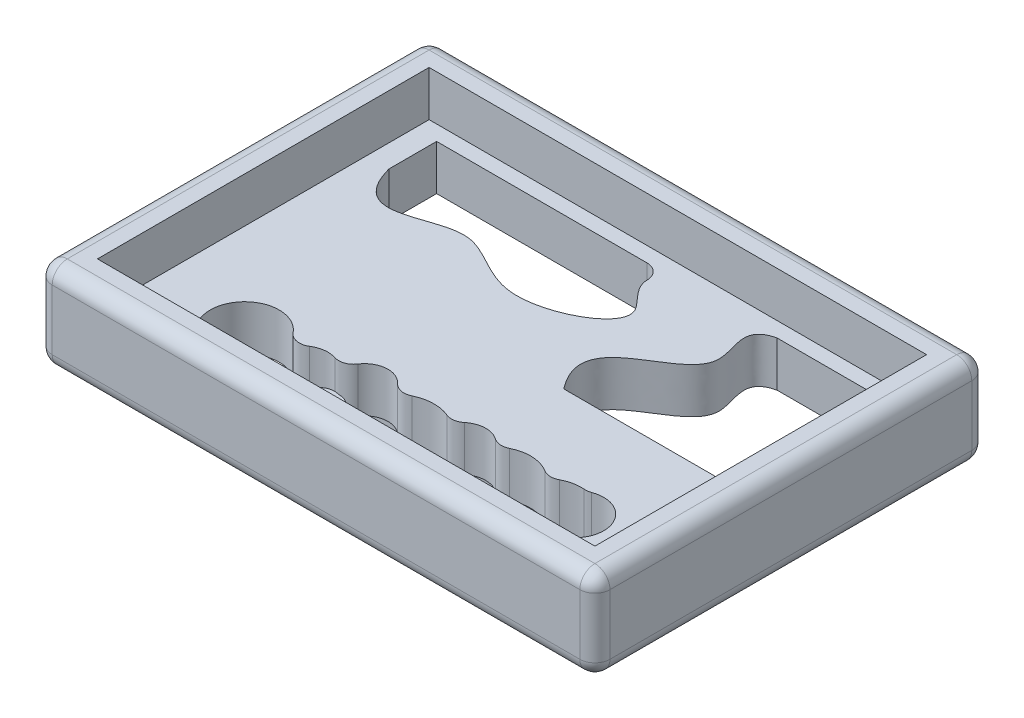
from build123d import *

# Parameters (mm, degrees)
SKETCH1_W           = 93.98
SKETCH1_H           = 66.04
SKETCH1_W_2         = 83.82
SKETCH1_H_2         = 55.88
BOSS_EXTRUDE1_DEPTH = 15.24
SKETCH3_W           = 83.82
SKETCH3_H           = 55.88
BOSS_EXTRUDE2_DEPTH = 7.62
BOSS_EXTRUDE3_DEPTH = 10
FILLET1_R           = 2.54
CUT_EXTRUDE1_DEPTH  = 16.24


with BuildPart() as part:
    # Sketch1 → Boss-Extrude1 (new body)
    with BuildSketch(Plane(origin=(0, 0, 0), x_dir=(1, 0, 0), z_dir=(0, 1, 0))):
        Rectangle(SKETCH1_W, SKETCH1_H)
        Rectangle(SKETCH1_W_2, SKETCH1_H_2, mode=Mode.SUBTRACT)
    extrude(amount=BOSS_EXTRUDE1_DEPTH)

    # Sketch3 → Boss-Extrude2 (add)
    with BuildSketch(Plane(origin=(0, 0, 0), x_dir=(1, 0, 0), z_dir=(0, 1, 0))):
        Rectangle(SKETCH3_W, SKETCH3_H)
    extrude(amount=BOSS_EXTRUDE2_DEPTH)

    # Sketch4 → Boss-Extrude3 (add)
    with BuildSketch(Plane.XZ):
        with BuildLine():
            Line((-30.48, 7.62), (30.48, 7.62))
            ThreePointArc((30.48, 7.62), (31.75, 6.35), (30.48, 5.08))
            Line((30.48, 5.08), (-30.48, 5.08))
            ThreePointArc((-30.48, 5.08), (-31.75, 6.35), (-30.48, 7.62))
        make_face()
    extrude(amount=BOSS_EXTRUDE3_DEPTH)

    # Fillet1
    fillet1_edges = [part.edges().sort_by_distance(p)[0] for p in [
        (46.99, 15.24, 0),
        (0, 15.24, -33.02),
        (-46.99, 15.24, 0),
        (0, 0, -33.02),
        (46.99, 0, 0),
        (0, 0, 33.02),
        (-46.99, 0, 0),
        (-46.99, 7.62, -33.02),
        (46.99, 7.62, -33.02),
        (46.99, 7.62, 33.02),
        (-46.99, 7.62, 33.02),
        (0, 15.24, 33.02),
    ]]
    fillet(fillet1_edges, radius=FILLET1_R)

    # Sketch5 → Cut-Extrude1 (cut, through all)
    with BuildSketch(Plane.XZ):
        with BuildLine():
            Line((38.1, 0), (8.720286281, 0))
            add(Edge.make_bspline(
                [(8.720286281, 0), (0.717932636, -10.320966423), (24.690327376, -11.221788079), (14.302617373, -24.27956655), (19.287221421, -25.4)],
                knots=[0, 0, 0, 0, 0.689243554, 1, 1, 1, 1], degree=3))
            Line((19.287221421, -25.4), (38.1, -25.4))
            Line((38.1, -25.4), (38.1, 0))
        make_face()
        with BuildLine():
            add(Edge.make_bspline(
                [(-38.1, -17.337980958), (-35.187970865, -6.837732589), (-22.396079464, -19.547216799), (-11.076568018, -5.424698839), (8.04848315, -15.407822573), (0.32989112, -20.213116903), (-0.131881687, -22.594944987), (-0.12685046, -22.796669294)],
                knots=[0, 0, 0, 0, 0.327916539, 0.565865574, 0.827054789, 0.928649045, 0.941908126, 0.941908126, 0.941908126, 0.941908126], degree=3))
            Line((-38.1, -17.337980958), (-38.1, -25.4))
            Line((-38.1, -25.4), (-2.666060814, -25.4))
            ThreePointArc((-2.666060814, -25.4), (-0.84775666, -24.633519101), (-0.12685046, -22.796669294))
        make_face()
        with BuildLine():
            ThreePointArc((-20.809664595, 23.563761473), (-23.399285475, 24.661043475), (-26.141098135, 24.03444358))
            ThreePointArc((-26.141098135, 24.03444358), (-32.141459521, 16.03667712), (-22.24223462, 14.631703292))
            ThreePointArc((-22.24223462, 14.631703292), (-20.680528135, 15.549204987), (-18.904626197, 15.192962357))
            ThreePointArc((-18.904626197, 15.192962357), (-17.075188661, 14.538079772), (-15.140614659, 14.720113645))
            ThreePointArc((-15.140614659, 14.720113645), (-13.518109108, 14.699820982), (-12.238965098, 13.701458994))
            ThreePointArc((-12.238965098, 13.701458994), (-9.256805246, 11.946815164), (-6.043815629, 13.230851799))
            ThreePointArc((-6.043815629, 13.230851799), (-4.644606266, 14.021459072), (-3.050933479, 13.813965102))
            ThreePointArc((-3.050933479, 13.813965102), (-0.202264641, 13.116417687), (2.681966092, 13.648112737))
            ThreePointArc((2.681966092, 13.648112737), (4.032557322, 13.814175625), (5.275046214, 13.259292838))
            ThreePointArc((5.275046214, 13.259292838), (7.732359851, 12.317746114), (10.257976284, 13.056773974))
            ThreePointArc((10.257976284, 13.056773974), (11.524940775, 13.507829697), (12.844614733, 13.248771918))
            ThreePointArc((12.844614733, 13.248771918), (15.999143067, 12.5855131), (19.076925277, 13.543749992))
            ThreePointArc((19.076925277, 13.543749992), (20.340690392, 13.925639815), (21.625421379, 13.621652327))
            ThreePointArc((21.625421379, 13.621652327), (23.29387293, 13.01462201), (25.066504565, 12.914654647))
            ThreePointArc((25.066504565, 12.914654647), (25.635512485, 12.901960546), (26.187409107, 12.762887643))
            ThreePointArc((26.187409107, 12.762887643), (32.302173237, 15.205977496), (30.433254549, 21.519943868))
            ThreePointArc((30.433254549, 21.519943868), (29.982257618, 21.867122384), (29.619886936, 22.306005788))
            ThreePointArc((29.619886936, 22.306005788), (26.018947716, 24.881341954), (21.625421379, 24.337240894))
            ThreePointArc((21.625421379, 24.337240894), (20.340690392, 24.033253406), (19.076925277, 24.415143229))
            ThreePointArc((19.076925277, 24.415143229), (13.537462145, 25.005428585), (9.633287177, 21.031575742))
            add(Edge.make_bspline(
                [(8.636564486, 20.482159427), (9.365510622, 20.380358696), (9.633287177, 21.031575742)],
                knots=[0, 0, 0, 1, 1, 1], degree=2))
            ThreePointArc((8.636564486, 20.482159427), (7.41195629, 21.075462315), (6.669321907, 22.215711291))
            ThreePointArc((6.669321907, 22.215711291), (-0.249726214, 27.097956484), (-6.802730996, 21.734406043))
            ThreePointArc((-6.802730996, 21.734406043), (-7.651745104, 20.369846866), (-9.149857761, 19.788034897))
            ThreePointArc((-9.149857761, 19.788034897), (-9.457684051, 19.760912808), (-9.762426275, 19.709679919))
            ThreePointArc((-9.762426275, 19.709679919), (-11.373542368, 19.902659169), (-12.539082341, 21.031575742))
            ThreePointArc((-12.539082341, 21.031575742), (-14.960654672, 23.176356644), (-18.19513891, 23.129352581))
            ThreePointArc((-18.19513891, 23.129352581), (-19.563553579, 22.978509725), (-20.809664595, 23.563761473))
        make_face()
    extrude(amount=-CUT_EXTRUDE1_DEPTH, mode=Mode.SUBTRACT)


solid = part.part
